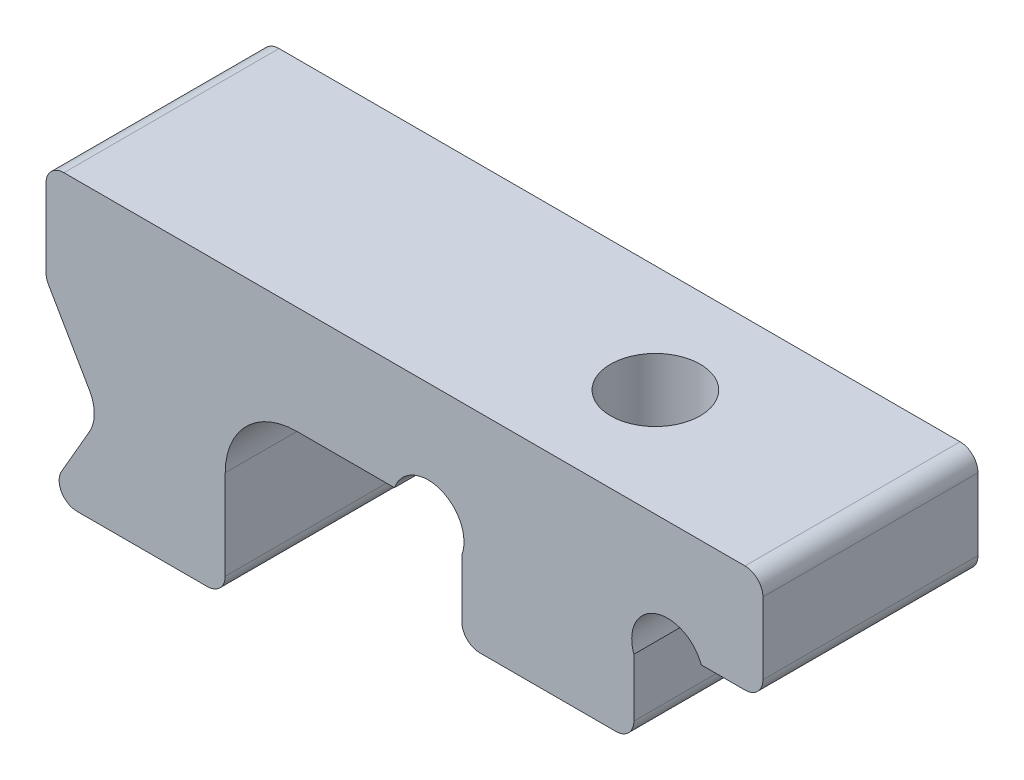
from build123d import *

# Parameters (mm, degrees)
BOSS_EXTRU_1_DEPTH      = 3
ESQUISSE2_R             = 1.25
ENL_V_MAT_EXTRU_1_DEPTH = 6.8
ESQUISSE3_W             = 6
ESQUISSE3_H             = 3
BOSS_EXTRU_2_DEPTH      = 8
ESQUISSE6_W             = 5
ESQUISSE6_H             = 6
BOSS_EXTRU_4_DEPTH      = 5
ENL_V_MAT_EXTRU_3_DEPTH = 7
CONG_2_R                = 0.5
CONG_3_R                = 2
CONG_4_R                = 1
ENL_V_MAT_EXTRU_4_DEPTH = 7


with BuildPart() as part:
    # Esquisse1 → Boss.-Extru.1 (new body, symmetric)
    with BuildSketch(Plane.XY):
        Polygon((-6, 0), (-2.4, 0), (-2.4, -2.8), (2.4, -2.8), (2.4, 0), (6, 0), (6, 3), (-6, 3), align=None)
    extrude(amount=BOSS_EXTRU_1_DEPTH, both=True)

    # Esquisse2 → Enlèv. mat.-Extru.1 (cut, through all)
    with BuildSketch(Plane(origin=(0, 3, 0), x_dir=(1, 0, 0), z_dir=(0, 1, 0))):
        Circle(ESQUISSE2_R)
    extrude(amount=-ENL_V_MAT_EXTRU_1_DEPTH, mode=Mode.SUBTRACT)

    # Esquisse3 → Boss.-Extru.2 (add)
    with BuildSketch(Plane.ZY.offset(6)):
        with Locations((0, 1.5)):
            Rectangle(ESQUISSE3_W, ESQUISSE3_H)
    extrude(amount=BOSS_EXTRU_2_DEPTH)

    # Esquisse6 → Boss.-Extru.4 (add)
    with BuildSketch(Plane.XZ):
        with Locations((-11.5, 0)):
            Rectangle(ESQUISSE6_W, ESQUISSE6_H)
    extrude(amount=BOSS_EXTRU_4_DEPTH)

    # Esquisse7 → Enlèv. mat.-Extru.3 (cut, through all)
    with BuildSketch(Plane.XY.offset(3)):
        Polygon((-14, 0.2), (-12.4988893, -2.4), (-14, -5), align=None)
    extrude(amount=-ENL_V_MAT_EXTRU_3_DEPTH, mode=Mode.SUBTRACT)

    # Congé2
    cong_2_edges = [part.edges().sort_by_distance(p)[0] for p in [
        (6, 0, 0),
        (2.4, -2.8, 0),
        (-2.4, -2.8, 0),
        (6, 3, 0),
        (-14, 3, 0),
        (-14, -5, 0),
        (-9, -5, 0),
        (-14, 0.2, 0),
    ]]
    fillet(cong_2_edges, radius=CONG_2_R)

    # Congé3
    cong_3_edges = [part.edges().sort_by_distance(p)[0] for p in [
        (-9, 0, 0),
    ]]
    fillet(cong_3_edges, radius=CONG_3_R)

    # Congé4
    cong_4_edges = [part.edges().sort_by_distance(p)[0] for p in [
        (-12.4988893, -2.4, 0),
    ]]
    fillet(cong_4_edges, radius=CONG_4_R)

    # Esquisse9 → Enlèv. mat.-Extru.4 (cut, through all)
    with BuildSketch(Plane(origin=(0, 0, -3), x_dir=(-1, 0, 0), z_dir=(0, 0, -1))):
        with BuildLine():
            Line((-4.279385242, 0), (-2.4, -0.684040287))
            ThreePointArc((-2.4, -0.684040287), (-2.997672477, 0.597672477), (-4.279385242, 0))
        make_face()
        with BuildLine():
            Line((4.279385242, 0), (2.4, -0.684040287))
            ThreePointArc((2.4, -0.684040287), (2.997672477, 0.597672477), (4.279385242, 0))
        make_face()
    extrude(amount=-ENL_V_MAT_EXTRU_4_DEPTH, mode=Mode.SUBTRACT)


solid = part.part
